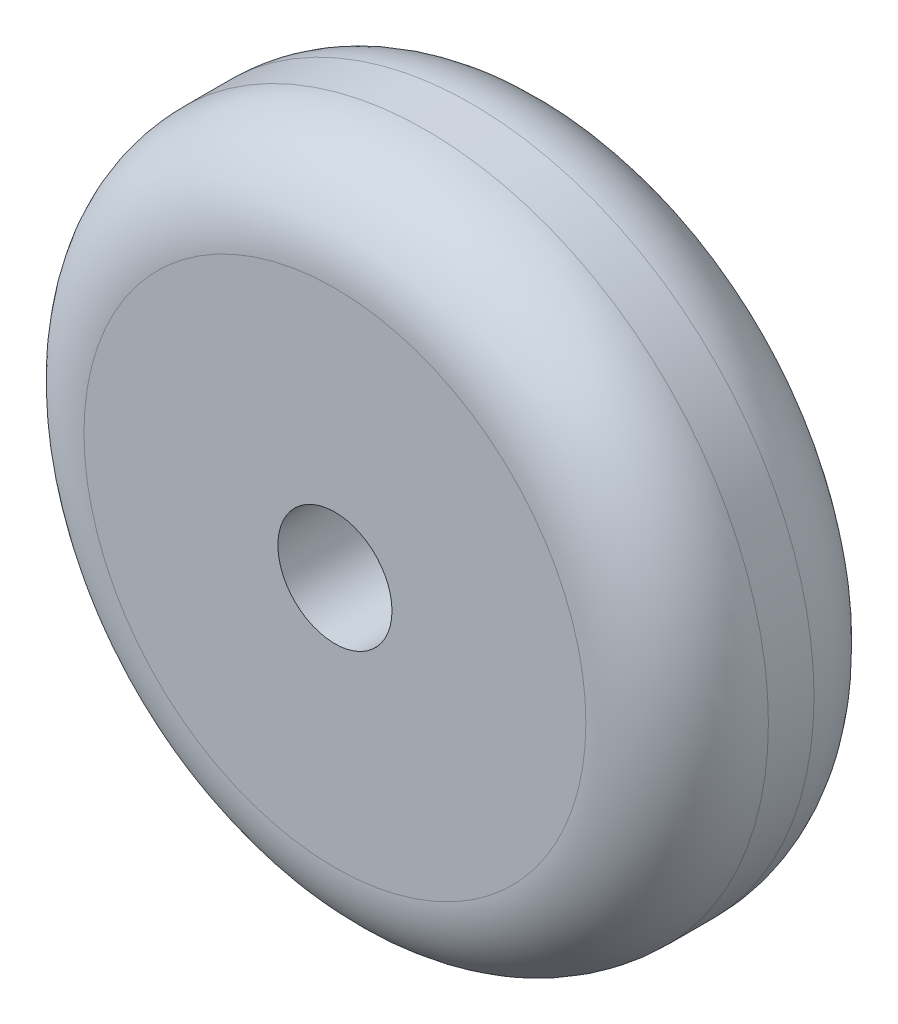
from build123d import *

# Parameters (mm, degrees)
SKETCH1_R           = 75
BOSS_EXTRUDE1_DEPTH = 50
FILLET2_R           = 20
FILLET3_R           = 20
SKETCH2_R           = 12.5
CUT_EXTRUDE1_DEPTH  = 51


with BuildPart() as part:
    # Sketch1 → Boss-Extrude1 (new body)
    with BuildSketch(Plane.XY):
        Circle(SKETCH1_R)
    extrude(amount=BOSS_EXTRUDE1_DEPTH)

    # Fillet2
    fillet2_edges = [part.edges().sort_by_distance(p)[0] for p in [
        (-75, 0, 50),
    ]]
    fillet(fillet2_edges, radius=FILLET2_R)

    # Fillet3
    fillet3_edges = [part.edges().sort_by_distance(p)[0] for p in [
        (-75, 0, 0),
    ]]
    fillet(fillet3_edges, radius=FILLET3_R)

    # Sketch2 → Cut-Extrude1 (cut, through all)
    with BuildSketch(Plane.XY.offset(50)):
        Circle(SKETCH2_R)
    extrude(amount=-CUT_EXTRUDE1_DEPTH, mode=Mode.SUBTRACT)


solid = part.part
